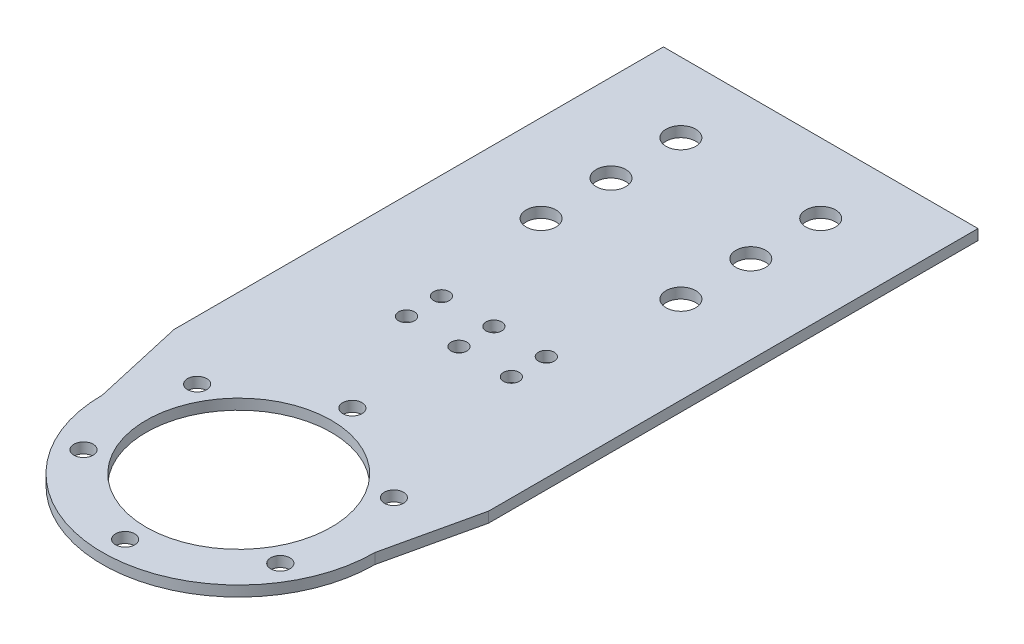
from build123d import *

# Parameters (mm, degrees)
SKETCH1_R            = 39
SKETCH1_R_2          = 26.5
BOSS_EXTRUDE1_DEPTH  = 1.5
SKETCH3_W            = 50
SKETCH3_H            = 51.5
BOSS_EXTRUDE2_DEPTH  = 1.5
BOSS_EXTRUDE4_DEPTH  = 1.5
SKETCH2_R            = 2.75
CUT_EXTRUDE1_DEPTH   = 173.480433673
CIRPATTERN1_COUNT    = 6
SKETCH5_R            = 2.25
CUT_EXTRUDE2_DEPTH   = 173.5
LPATTERN1_COUNT      = 2
LPATTERN1_PITCH      = 15
LPATTERN1_COUNT_DIR2 = 2
LPATTERN1_PITCH_DIR2 = 10
LPATTERN2_COUNT      = 2
LPATTERN2_PITCH      = 15
LPATTERN2_COUNT_DIR2 = 2
LPATTERN2_PITCH_DIR2 = 10
SKETCH7_R            = 4.25
CUT_EXTRUDE3_DEPTH   = 173.5
LPATTERN3_COUNT      = 3
LPATTERN3_PITCH      = 20


with BuildPart() as part:
    # Sketch1 → Boss-Extrude1 (new, symmetric)
    with BuildSketch(Plane(origin=(0, 0, 0), x_dir=(1, 0, 0), z_dir=(0, 1, 0))):
        Circle(SKETCH1_R)
        Circle(SKETCH1_R_2, mode=Mode.SUBTRACT)
    extrude(amount=BOSS_EXTRUDE1_DEPTH, both=True)

    # Sketch3 → Boss-Extrude2 (add, symmetric)
    with BuildSketch(Plane(origin=(0, 0, 0), x_dir=(1, 0, 0), z_dir=(0, 1, 0))):
        with Locations((0, 52.25)):
            Rectangle(SKETCH3_W, SKETCH3_H)
    extrude(amount=BOSS_EXTRUDE2_DEPTH, both=True)

    # Sketch6 → Boss-Extrude4 (add, symmetric)
    with BuildSketch(Plane(origin=(0, 0, 0), x_dir=(1, 0, 0), z_dir=(0, 1, 0))):
        Polygon((-45, 166.5), (-45, 26.5), (-39, 0), (-14.981514186, 26.5), (16.520833333, 26.5), (39, 0), (45, 26.5), (45, 166.5), align=None)
    extrude(amount=BOSS_EXTRUDE4_DEPTH, both=True)

    # Sketch2 → Cut-Extrude1 (cut, symmetric)
    with BuildSketch(Plane(origin=(0, 0, 0), x_dir=(1, 0, 0), z_dir=(0, 1, 0))):
        with Locations((0, 32.5)):
            Circle(SKETCH2_R)
    cut_extrude1 = extrude(amount=CUT_EXTRUDE1_DEPTH, both=True, mode=Mode.SUBTRACT)

    # CirPattern1: Cut-Extrude1 ×6 about axis
    cirpattern1_axis = Axis((0, 1.5, 0), (0, 1, 0))
    for i in range(1, CIRPATTERN1_COUNT):
        add(cut_extrude1.rotate(cirpattern1_axis, i * 360 / CIRPATTERN1_COUNT), mode=Mode.SUBTRACT)

    # Sketch5 → Cut-Extrude2 (cut, symmetric)
    with BuildSketch(Plane(origin=(0, 1.5, 0), x_dir=(1, 0, 0), z_dir=(0, 1, 0))):
        with Locations((0, 73)):
            Circle(SKETCH5_R)
    cut_extrude2 = extrude(amount=CUT_EXTRUDE2_DEPTH, both=True, mode=Mode.SUBTRACT)

    # LPattern1: Cut-Extrude2 2 × 2
    with Locations(*[(i * LPATTERN1_PITCH, 0, j * LPATTERN1_PITCH_DIR2) for i in range(LPATTERN1_COUNT) for j in range(LPATTERN1_COUNT_DIR2) if (i, j) != (0, 0)]):
        add(cut_extrude2, mode=Mode.SUBTRACT)

    # LPattern2: Cut-Extrude2 2 × 2
    with Locations(*[(-i * LPATTERN2_PITCH, 0, j * LPATTERN2_PITCH_DIR2) for i in range(LPATTERN2_COUNT) for j in range(LPATTERN2_COUNT_DIR2) if (i, j) != (0, 0)]):
        add(cut_extrude2, mode=Mode.SUBTRACT)

    # Sketch7 → Cut-Extrude3 (cut, symmetric)
    with BuildSketch(Plane(origin=(0, 1.5, 0), x_dir=(1, 0, 0), z_dir=(0, 1, 0))):
        with Locations((-20, 146.5)):
            Circle(SKETCH7_R)
        with Locations((20, 146.5)):
            Circle(SKETCH7_R)
    cut_extrude3 = extrude(amount=CUT_EXTRUDE3_DEPTH, both=True, mode=Mode.SUBTRACT)

    # LPattern3: Cut-Extrude3 ×3
    with Locations(*[(0, 0, i * LPATTERN3_PITCH) for i in range(1, LPATTERN3_COUNT)]):
        add(cut_extrude3, mode=Mode.SUBTRACT)


solid = part.part
